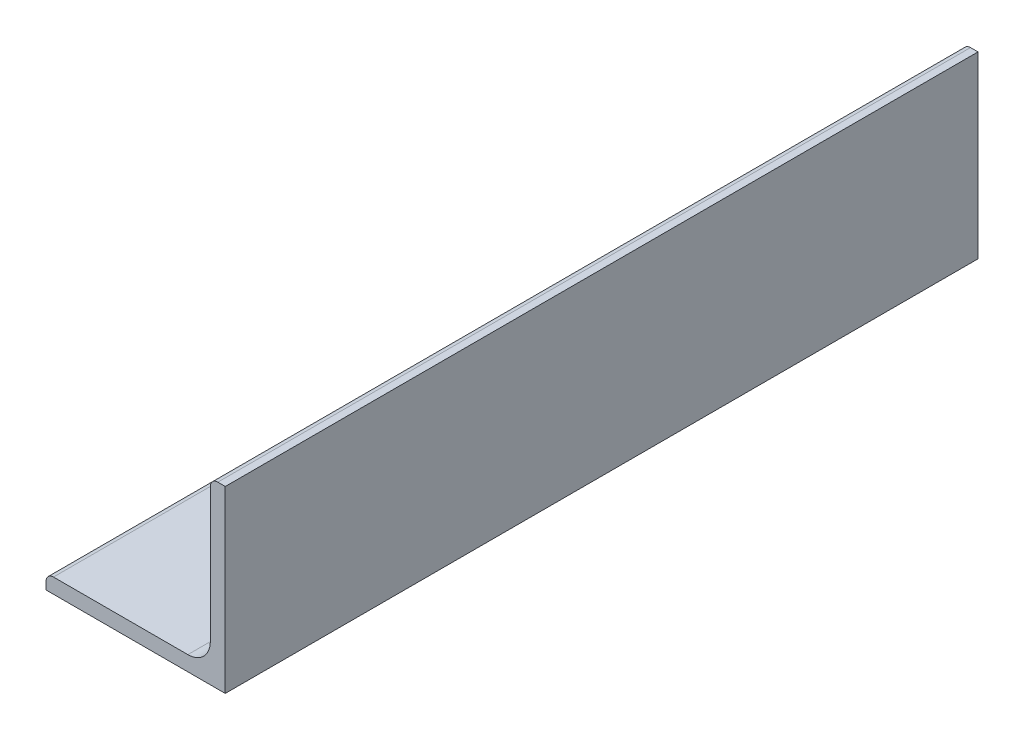
from build123d import *

# Parameters (mm, degrees)
BOSS_EXTRUDE1_DEPTH = 609.6
SKETCH3_W           = 635.2
SKETCH3_H           = 38.1
CUT_EXTRUDE1_DEPTH  = 60
SKETCH4_W           = 424
SKETCH4_H           = 38.1
CUT_EXTRUDE2_DEPTH  = 60


with BuildPart() as part:
    # Sketch2 → Boss-Extrude1 (new, symmetric)
    with BuildSketch(Plane.XY):
        with BuildLine():
            Line((-19.05, -19.05), (19.05, -19.05))
            Line((19.05, -19.05), (19.05, 19.05))
            Line((19.05, 19.05), (17.4625, 19.05))
            ThreePointArc((17.4625, 19.05), (16.339967985, 18.585032015), (15.875, 17.4625))
            Line((15.875, 17.4625), (15.875, -11.0998))
            ThreePointArc((15.875, -11.0998), (14.476376302, -14.476376302), (11.0998, -15.875))
            Line((11.0998, -15.875), (-17.4625, -15.875))
            ThreePointArc((-17.4625, -15.875), (-18.585032015, -16.339967985), (-19.05, -17.4625))
            Line((-19.05, -17.4625), (-19.05, -19.05))
        make_face()
    extrude(amount=BOSS_EXTRUDE1_DEPTH, both=True)

    # Sketch3 → Cut-Extrude1 (cut)
    with BuildSketch(Plane(origin=(19.05, 0, 0), x_dir=(0, 0, -1), z_dir=(1, 0, 0))):
        with Locations((292, 0)):
            Rectangle(SKETCH3_W, SKETCH3_H)
    extrude(amount=-CUT_EXTRUDE1_DEPTH, mode=Mode.SUBTRACT)

    # Sketch4 → Cut-Extrude2 (cut)
    with BuildSketch(Plane(origin=(19.05, 0, 0), x_dir=(0, 0, -1), z_dir=(1, 0, 0))):
        with Locations((-237.6, 0)):
            Rectangle(SKETCH4_W, SKETCH4_H)
    extrude(amount=-CUT_EXTRUDE2_DEPTH, mode=Mode.SUBTRACT)


solid = part.part
